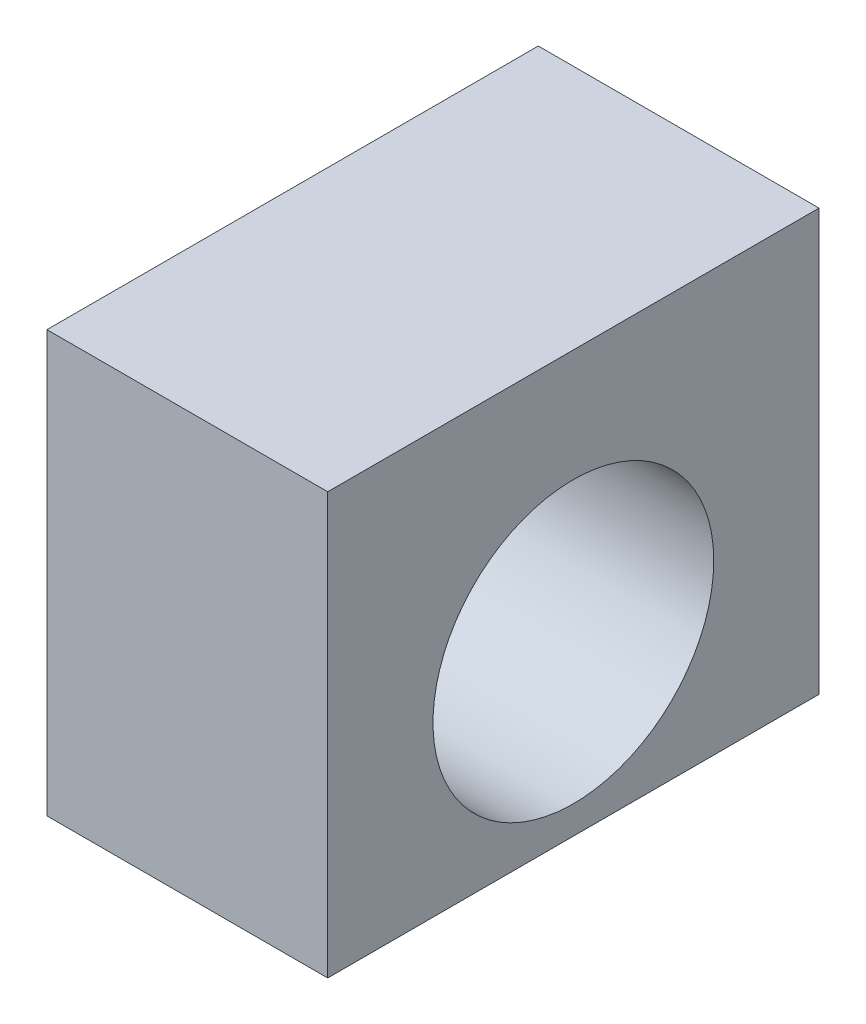
from build123d import *

# Parameters (mm, degrees)
SKETCH1_W           = 22.225
SKETCH1_H           = 19.05
SKETCH1_R           = 6.35
BOSS_EXTRUDE1_DEPTH = 12.7


with BuildPart() as part:
    # Sketch1 → Boss-Extrude1 (new body)
    with BuildSketch(Plane(origin=(0, 0, 0), x_dir=(0, 0, -1), z_dir=(1, 0, 0))):
        with Locations((11.1125, -9.525)):
            Rectangle(SKETCH1_W, SKETCH1_H)
        with Locations((11.1125, -11.43)):
            Circle(SKETCH1_R, mode=Mode.SUBTRACT)
    extrude(amount=BOSS_EXTRUDE1_DEPTH)


solid = part.part
